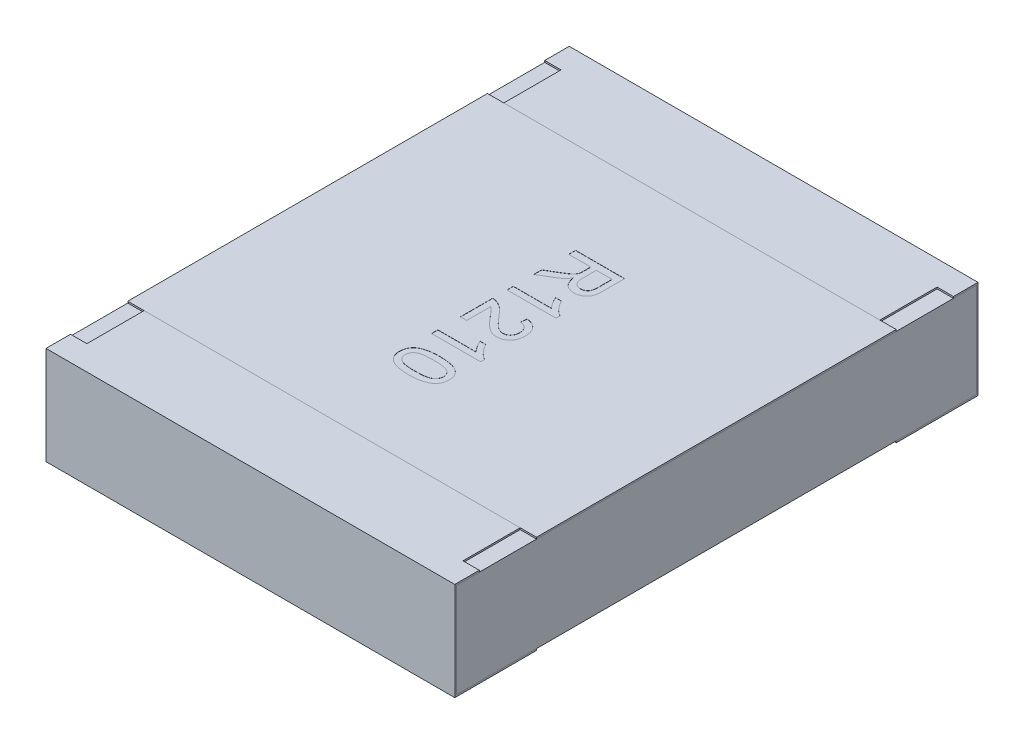
from build123d import *

# Parameters (mm, degrees)
BOSS_EXTRUDE2_DEPTH   = 1.25
BOSS_EXTRUDE2_2_DEPTH = 1.25
BOSS_EXTRUDE3_START   = -1.25
SKETCH5_W             = 3.18
SKETCH5_H             = 0.58
BOSS_EXTRUDE3_DEPTH   = 2.5
SKETCH6_W             = 0.1
SKETCH6_H             = 0.35
CUT_EXTRUDE1_DEPTH    = 0.01
SKETCH7_W             = 2.5
SKETCH7_H             = 2.2
BOSS_EXTRUDE4_DEPTH   = 0.01
TEXT1210_DEPTH        = 0.001


with BuildPart() as part:
    # Sketch4 → Boss-Extrude2 (new body, symmetric)
    with BuildSketch(Plane(origin=(0, 0, 0), x_dir=(0, 0, -1), z_dir=(1, 0, 0))):
        Polygon((-1.6, 0.3), (-1.6, -0.3), (-1.1, -0.3), (-1.1, -0.29), (-1.59, -0.29), (-1.59, 0.29), (-1.1, 0.29), (-1.1, 0.3), align=None)
    extrude(amount=BOSS_EXTRUDE2_DEPTH, both=True)


with BuildPart() as body_2:
    # Sketch4 → Boss-Extrude2 2 (new body, symmetric)
    with BuildSketch(Plane(origin=(0, 0, 0), x_dir=(0, 0, -1), z_dir=(1, 0, 0))):
        Polygon((1.1, 0.3), (1.6, 0.3), (1.6, -0.3), (1.1, -0.3), (1.1, -0.29), (1.59, -0.29), (1.59, 0.29), (1.1, 0.29), align=None)
    extrude(amount=BOSS_EXTRUDE2_2_DEPTH, both=True)


with BuildPart() as body_3:
    # Sketch5 → Boss-Extrude3 (new body)
    with BuildSketch(Plane(origin=(0, 0, 0), x_dir=(0, 0, -1), z_dir=(1, 0, 0)).offset(BOSS_EXTRUDE3_START)):
        Rectangle(SKETCH5_W, SKETCH5_H)
    extrude(amount=BOSS_EXTRUDE3_DEPTH)


with BuildPart() as cut_extrude1_tool:
    # Sketch6 → Cut-Extrude1 (new body)
    with BuildSketch(Plane(origin=(0, 0.3, 0), x_dir=(1, 0, 0), z_dir=(0, 1, 0))):
        with Locations((-1.2, 1.275)):
            Rectangle(SKETCH6_W, SKETCH6_H)
        with Locations((1.2, 1.275)):
            Rectangle(SKETCH6_W, SKETCH6_H)
        with Locations((1.2, -1.275)):
            Rectangle(SKETCH6_W, SKETCH6_H)
        with Locations((-1.2, -1.275)):
            Rectangle(SKETCH6_W, SKETCH6_H)
    extrude(amount=-CUT_EXTRUDE1_DEPTH)


with BuildPart() as part_1:
    add(part.part)

    # Cut-Extrude1: cut by cut_extrude1_tool
    add(cut_extrude1_tool.part, mode=Mode.SUBTRACT)


with BuildPart() as body_2_1:
    add(body_2.part)

    # Cut-Extrude1: cut by cut_extrude1_tool
    add(cut_extrude1_tool.part, mode=Mode.SUBTRACT)


with BuildPart() as body_4:
    # Sketch7 → Boss-Extrude4 (new body)
    with BuildSketch(Plane(origin=(0, 0.29, 0), x_dir=(1, 0, 0), z_dir=(0, 1, 0))):
        Rectangle(SKETCH7_W, SKETCH7_H)
    extrude(amount=BOSS_EXTRUDE4_DEPTH)

    # Sketch13 → TEXT1210 (cut)
    with BuildSketch(Plane(origin=(0, 0.3, 0), x_dir=(1, 0, 0), z_dir=(0, 1, 0))):
        with BuildLine():
            Line((-0.15, 0.53890045), (0.15, 0.53890045))
            Line((0.15, 0.53890045), (0.15, 0.408732181))
            add(Edge.make_bspline(
                [(0.15, 0.408732181), (0.149976098, 0.405667102), (0.149929838, 0.399735001), (0.149599275, 0.391132467), (0.148896994, 0.383121837), (0.148112632, 0.375652624), (0.146954506, 0.368737608), (0.145595815, 0.362373494), (0.14399, 0.356584693), (0.142091864, 0.351327149), (0.139945096, 0.346448918), (0.137294925, 0.34192838), (0.134395694, 0.337571787), (0.130961971, 0.333551483), (0.12726979, 0.329691487), (0.123136626, 0.326123702), (0.118620847, 0.322830716), (0.112164906, 0.318767466), (0.103522968, 0.314492001), (0.092520499, 0.310842903), (0.080987257, 0.308509851), (0.073108187, 0.308258664), (0.069110577, 0.308131219)],
                knots=[0, 0, 0, 0, 9.195e-06, 1.7797e-05, 2.5817e-05, 3.3316e-05, 4.0321e-05, 4.6839e-05, 5.2832e-05, 5.8326e-05, 6.3598e-05, 6.8794e-05, 7.4028e-05, 7.9275e-05, 8.463e-05, 9.0041e-05, 9.563e-05, 0.000101382, 0.000112912, 0.000124447, 0.00013608, 0.000148061, 0.000148061, 0.000148061, 0.000148061], degree=3))
            add(Edge.make_bspline(
                [(0.069110577, 0.308131219), (0.066544329, 0.308189925), (0.061475814, 0.308305871), (0.054023732, 0.309194023), (0.046903597, 0.310801096), (0.040052911, 0.312861739), (0.033569258, 0.315682545), (0.027318263, 0.318948853), (0.021478898, 0.323000974), (0.015856738, 0.327525677), (0.010702727, 0.332785954), (0.00594759, 0.338641486), (0.001839276, 0.345239643), (-0.001852779, 0.35245901), (-0.005083582, 0.360312684), (-0.007800008, 0.368852892), (-0.009926689, 0.378049394), (-0.010991982, 0.384426942), (-0.011538462, 0.387698527)],
                knots=[0, 0, 0, 0, 7.698e-06, 1.5204e-05, 2.2466e-05, 2.9575e-05, 3.663e-05, 4.3647e-05, 5.0697e-05, 5.7915e-05, 6.5267e-05, 7.2747e-05, 8.05e-05, 8.8536e-05, 9.7051e-05, 0.000105946, 0.000115392, 0.000125341, 0.000125341, 0.000125341, 0.000125341], degree=3))
            add(Edge.make_bspline(
                [(-0.011538462, 0.387698527), (-0.012753772, 0.385280306), (-0.01505392, 0.380703478), (-0.018746634, 0.374390533), (-0.022400996, 0.368969486), (-0.025073191, 0.365842638), (-0.026322115, 0.364381219)],
                knots=[0, 0, 0, 0, 8.117e-06, 1.5363e-05, 2.1931e-05, 2.7694e-05, 2.7694e-05, 2.7694e-05, 2.7694e-05], degree=3))
            add(Edge.make_bspline(
                [(-0.026322115, 0.364381219), (-0.029096413, 0.36154242), (-0.034786041, 0.355720511), (-0.044567018, 0.347775756), (-0.055323294, 0.339914515), (-0.06316159, 0.33519479), (-0.0671875, 0.332770643)],
                knots=[0, 0, 0, 0, 1.1899e-05, 2.4402e-05, 3.7746e-05, 5.1837e-05, 5.1837e-05, 5.1837e-05, 5.1837e-05], degree=3))
            Line((-0.0671875, 0.332770643), (-0.15, 0.283551893))
            Line((-0.15, 0.283551893), (-0.15, 0.332049489))
            Line((-0.15, 0.332049489), (-0.086658654, 0.369429296))
            add(Edge.make_bspline(
                [(-0.086658654, 0.369429296), (-0.084436284, 0.370773342), (-0.080129696, 0.373377881), (-0.073839518, 0.377139139), (-0.068050631, 0.380830263), (-0.062587585, 0.384242535), (-0.057592425, 0.387558482), (-0.052916134, 0.390591892), (-0.048743568, 0.393576151), (-0.043718189, 0.397046883), (-0.038248453, 0.401231353), (-0.03266463, 0.406147392), (-0.028105288, 0.410708943), (-0.02370073, 0.416416065), (-0.019596578, 0.423497827), (-0.017689234, 0.429504964), (-0.016766827, 0.432410066)],
                knots=[0, 0, 0, 0, 7.792e-06, 1.5099e-05, 2.1985e-05, 2.8387e-05, 3.4421e-05, 3.9972e-05, 4.5107e-05, 4.9808e-05, 5.8294e-05, 6.5746e-05, 7.212e-05, 7.7602e-05, 8.7344e-05, 9.6468e-05, 9.6468e-05, 9.6468e-05, 9.6468e-05], degree=3))
            add(Edge.make_bspline(
                [(-0.016766827, 0.432410066), (-0.016546925, 0.433629479), (-0.016044883, 0.436413437), (-0.015716998, 0.44114059), (-0.015368993, 0.446868117), (-0.015379133, 0.451018953), (-0.015384615, 0.453263431)],
                knots=[0, 0, 0, 0, 3.715e-06, 8.481e-06, 1.4198e-05, 2.0929e-05, 2.0929e-05, 2.0929e-05, 2.0929e-05], degree=3))
            Line((-0.015384615, 0.453263431), (-0.015384615, 0.496592758))
            Line((-0.015384615, 0.496592758), (-0.15, 0.496592758))
            Line((-0.15, 0.496592758), (-0.15, 0.53890045))
        make_face()
        with BuildLine():
            Line((0.019230769, 0.496592758), (0.019230769, 0.4162442))
            add(Edge.make_bspline(
                [(0.019230769, 0.4162442), (0.019294059, 0.412215272), (0.019412374, 0.404683569), (0.020415568, 0.394150896), (0.022027239, 0.385158399), (0.02434032, 0.377538233), (0.027566204, 0.371139631), (0.031574247, 0.36564263), (0.036450959, 0.360966228), (0.042058536, 0.357144318), (0.048176988, 0.354134087), (0.054649472, 0.352079121), (0.061335975, 0.350647439), (0.06589779, 0.350509036), (0.068209135, 0.350438912)],
                knots=[0, 0, 0, 0, 1.2085e-05, 2.2591e-05, 3.1702e-05, 3.9457e-05, 4.6391e-05, 5.3098e-05, 5.9771e-05, 6.6555e-05, 7.3382e-05, 8.0147e-05, 8.6889e-05, 9.3813e-05, 9.3813e-05, 9.3813e-05, 9.3813e-05], degree=3))
            add(Edge.make_bspline(
                [(0.068209135, 0.350438912), (0.069893078, 0.35049475), (0.073191429, 0.350604121), (0.078032493, 0.351177478), (0.082632622, 0.352292221), (0.087016134, 0.353764235), (0.091150922, 0.355731146), (0.095069027, 0.358067756), (0.098748733, 0.360856052), (0.102201249, 0.364049886), (0.1053427, 0.367716987), (0.108053092, 0.371905678), (0.11035634, 0.376582924), (0.112184352, 0.381754161), (0.113646463, 0.387403099), (0.114619159, 0.393561896), (0.115322998, 0.400202386), (0.115363693, 0.40480386), (0.115384615, 0.407169681)],
                knots=[0, 0, 0, 0, 5.054e-06, 9.899e-06, 1.4593e-05, 1.923e-05, 2.3746e-05, 2.8302e-05, 3.2893e-05, 3.757e-05, 4.2387e-05, 4.7338e-05, 5.2498e-05, 5.7992e-05, 6.3764e-05, 6.9978e-05, 7.6682e-05, 8.3775e-05, 8.3775e-05, 8.3775e-05, 8.3775e-05], degree=3))
            Line((0.115384615, 0.407169681), (0.115384615, 0.496592758))
            Line((0.115384615, 0.496592758), (0.019230769, 0.496592758))
        make_face(mode=Mode.SUBTRACT)
        with BuildLine():
            Line((-0.15, 0.119669681), (-0.15, 0.158131219))
            Line((-0.15, 0.158131219), (0.083774038, 0.158131219))
            add(Edge.make_bspline(
                [(0.083774038, 0.158131219), (0.081638509, 0.160345965), (0.077200045, 0.164949071), (0.070914564, 0.172727532), (0.064571645, 0.181407385), (0.058389404, 0.190844639), (0.052683492, 0.200538577), (0.047476916, 0.209878141), (0.043093554, 0.218732882), (0.040694469, 0.224563953), (0.039543269, 0.227361989)],
                knots=[0, 0, 0, 0, 9.226e-06, 1.9175e-05, 2.9969e-05, 4.147e-05, 5.3003e-05, 6.3709e-05, 7.3546e-05, 8.262e-05, 8.262e-05, 8.262e-05, 8.262e-05], degree=3))
            Line((0.039543269, 0.227361989), (0.075, 0.227361989))
            add(Edge.make_bspline(
                [(0.075, 0.227361989), (0.077475162, 0.222555868), (0.082353558, 0.21308329), (0.09077922, 0.199700585), (0.099912985, 0.18720639), (0.10975283, 0.175807534), (0.119810917, 0.165589186), (0.129959923, 0.156978036), (0.139827828, 0.149772773), (0.146709597, 0.146157756), (0.15, 0.144429296)],
                knots=[0, 0, 0, 0, 1.6212e-05, 3.1953e-05, 4.7386e-05, 6.26e-05, 7.7091e-05, 9.0349e-05, 0.000102505, 0.000113642, 0.000113642, 0.000113642, 0.000113642], degree=3))
            Line((0.15, 0.144429296), (0.15, 0.119669681))
            Line((0.15, 0.119669681), (-0.15, 0.119669681))
        make_face()
        with BuildLine():
            Line((-0.111538462, -0.164945704), (-0.15, -0.164945704))
            Line((-0.15, -0.164945704), (-0.15, 0.031208143))
            add(Edge.make_bspline(
                [(-0.15, 0.031208143), (-0.147714123, 0.031212158), (-0.14315003, 0.031220176), (-0.136400026, 0.030447858), (-0.129739566, 0.029238254), (-0.125468478, 0.027870554), (-0.123317308, 0.0271817)],
                knots=[0, 0, 0, 0, 6.852e-06, 1.3681e-05, 2.0352e-05, 2.7121e-05, 2.7121e-05, 2.7121e-05, 2.7121e-05], degree=3))
            add(Edge.make_bspline(
                [(-0.123317308, 0.0271817), (-0.119803316, 0.025907684), (-0.112648251, 0.023313576), (-0.102300861, 0.018077982), (-0.092077121, 0.011817442), (-0.083693742, 0.00582597), (-0.077044802, 0.000307816), (-0.071780052, -0.004242641), (-0.066458477, -0.00936864), (-0.06098519, -0.014976734), (-0.055359875, -0.02103289), (-0.049556317, -0.027536873), (-0.043684824, -0.034567952), (-0.039792869, -0.039476279), (-0.037800481, -0.041988973)],
                knots=[0, 0, 0, 0, 1.1205e-05, 2.2816e-05, 3.4709e-05, 4.7152e-05, 5.3684e-05, 6.0627e-05, 6.8023e-05, 7.5842e-05, 8.4134e-05, 9.2818e-05, 0.00010199, 0.00011161, 0.00011161, 0.00011161, 0.00011161], degree=3))
            add(Edge.make_bspline(
                [(-0.037800481, -0.041988973), (-0.034551471, -0.045849105), (-0.028295295, -0.053282033), (-0.019011711, -0.063778493), (-0.010391377, -0.073365301), (-0.002283205, -0.081889797), (0.005234162, -0.089421703), (0.012143692, -0.095978705), (0.018423822, -0.10161722), (0.024301865, -0.106268413), (0.029852373, -0.110192767), (0.035266551, -0.113518311), (0.040638972, -0.116289711), (0.045952637, -0.118597916), (0.05123027, -0.12042351), (0.056487246, -0.121667912), (0.061671403, -0.122511822), (0.065120999, -0.122596256), (0.066826923, -0.122638011)],
                knots=[0, 0, 0, 0, 1.5136e-05, 2.9145e-05, 4.2036e-05, 5.3811e-05, 6.4435e-05, 7.3957e-05, 8.2386e-05, 8.9745e-05, 9.643e-05, 0.000102769, 0.00010879, 0.00011455, 0.000120137, 0.000125516, 0.000130743, 0.000135857, 0.000135857, 0.000135857, 0.000135857], degree=3))
            add(Edge.make_bspline(
                [(0.066826923, -0.122638011), (0.068512943, -0.122596251), (0.071820821, -0.12251432), (0.076661881, -0.121736964), (0.081323937, -0.120654823), (0.085723062, -0.118905328), (0.089989535, -0.116822905), (0.093988521, -0.114151687), (0.097819766, -0.111061664), (0.101381944, -0.107523747), (0.104724786, -0.103659897), (0.107500012, -0.099341146), (0.110020859, -0.094841632), (0.111988045, -0.090012647), (0.113504097, -0.084897197), (0.114560258, -0.079503489), (0.115243078, -0.07381712), (0.115336721, -0.069935697), (0.115384615, -0.067950511)],
                knots=[0, 0, 0, 0, 5.054e-06, 9.915e-06, 1.4681e-05, 1.938e-05, 2.4083e-05, 2.89e-05, 3.3772e-05, 3.8829e-05, 4.3946e-05, 4.9063e-05, 5.4199e-05, 5.94e-05, 6.4667e-05, 7.0183e-05, 7.587e-05, 8.1825e-05, 8.1825e-05, 8.1825e-05, 8.1825e-05], degree=3))
            add(Edge.make_bspline(
                [(0.115384615, -0.067950511), (0.115336639, -0.065865248), (0.115242746, -0.061784233), (0.114561705, -0.055818238), (0.113515033, -0.050156984), (0.111941815, -0.044820663), (0.109882187, -0.039819946), (0.10742732, -0.035119384), (0.104518024, -0.030736949), (0.101139001, -0.026742772), (0.097458268, -0.023042921), (0.093296561, -0.01991736), (0.088872885, -0.017185193), (0.084046797, -0.015029859), (0.078924308, -0.013272117), (0.073429376, -0.012003371), (0.067585566, -0.011309945), (0.063583419, -0.011170699), (0.061538462, -0.01109955)],
                knots=[0, 0, 0, 0, 6.255e-06, 1.2241e-05, 1.7992e-05, 2.3507e-05, 2.8897e-05, 3.4193e-05, 3.9393e-05, 4.4641e-05, 4.9868e-05, 5.5012e-05, 6.0217e-05, 6.5434e-05, 7.0832e-05, 7.6444e-05, 8.2318e-05, 8.8455e-05, 8.8455e-05, 8.8455e-05, 8.8455e-05], degree=3))
            Line((0.061538462, -0.01109955), (0.065384615, 0.027361989))
            add(Edge.make_bspline(
                [(0.065384615, 0.027361989), (0.068736662, 0.026968514), (0.07525778, 0.026203042), (0.084702032, 0.024295587), (0.093489714, 0.021620518), (0.101734943, 0.018410007), (0.109336857, 0.014414645), (0.116323186, 0.009782788), (0.122725854, 0.004518046), (0.12839596, -0.001471261), (0.133571363, -0.007955893), (0.137925688, -0.015096713), (0.141698648, -0.022728063), (0.144749435, -0.030904258), (0.147087025, -0.039622088), (0.148758415, -0.048867975), (0.149789925, -0.058652385), (0.149928976, -0.065363809), (0.15, -0.068791857)],
                knots=[0, 0, 0, 0, 1.0123e-05, 1.9693e-05, 2.8857e-05, 3.7651e-05, 4.6199e-05, 5.4566e-05, 6.276e-05, 7.1006e-05, 7.9266e-05, 8.7604e-05, 9.6043e-05, 0.000104772, 0.000113738, 0.000123085, 0.000132934, 0.000143217, 0.000143217, 0.000143217, 0.000143217], degree=3))
            add(Edge.make_bspline(
                [(0.15, -0.068791857), (0.149940576, -0.072260911), (0.149824817, -0.079018649), (0.148641062, -0.08886594), (0.146795931, -0.098156453), (0.144229333, -0.106927372), (0.140839664, -0.115132097), (0.136757117, -0.122798722), (0.131911514, -0.12990297), (0.126324053, -0.136348396), (0.120221623, -0.142160815), (0.113705953, -0.147247068), (0.106829733, -0.151523142), (0.099612825, -0.155060041), (0.092008541, -0.157768278), (0.084045391, -0.159653026), (0.075742745, -0.160939575), (0.070077161, -0.161045516), (0.0671875, -0.16109955)],
                knots=[0, 0, 0, 0, 1.0403e-05, 2.0265e-05, 2.9705e-05, 3.8794e-05, 4.7633e-05, 5.6291e-05, 6.4808e-05, 7.3373e-05, 8.1833e-05, 9.0055e-05, 9.8126e-05, 0.000106082, 0.000114122, 0.000122285, 0.000130605, 0.000139266, 0.000139266, 0.000139266, 0.000139266], degree=3))
            add(Edge.make_bspline(
                [(0.0671875, -0.16109955), (0.064218398, -0.161018436), (0.05827364, -0.16085603), (0.049399233, -0.159540755), (0.040594357, -0.15742356), (0.03178904, -0.15448579), (0.02297561, -0.150397344), (0.013942435, -0.1453621), (0.004756402, -0.139068729), (-0.003111225, -0.133100478), (-0.009660413, -0.127481214), (-0.015062592, -0.122500411), (-0.020824791, -0.116739332), (-0.027059821, -0.110351181), (-0.033675497, -0.103205116), (-0.04077151, -0.095431357), (-0.048197577, -0.086875504), (-0.053269547, -0.080934925), (-0.055889423, -0.077866377)],
                knots=[0, 0, 0, 0, 8.904e-06, 1.7828e-05, 2.6851e-05, 3.6049e-05, 4.5623e-05, 5.5954e-05, 6.7039e-05, 7.8998e-05, 8.5562e-05, 9.292e-05, 0.000101036, 0.000110004, 0.000119698, 0.000130249, 0.000141579, 0.000153683, 0.000153683, 0.000153683, 0.000153683], degree=3))
            add(Edge.make_bspline(
                [(-0.055889423, -0.077866377), (-0.058028577, -0.075238679), (-0.062107615, -0.070228065), (-0.068021764, -0.063100065), (-0.073442596, -0.056713575), (-0.07820298, -0.05092774), (-0.082492694, -0.045938601), (-0.086224809, -0.04163915), (-0.089451821, -0.038072078), (-0.094402484, -0.03263426), (-0.10140021, -0.025694591), (-0.108253196, -0.020622443), (-0.111538462, -0.018190896)],
                knots=[0, 0, 0, 0, 1.0165e-05, 1.9383e-05, 2.7786e-05, 3.5295e-05, 4.1859e-05, 4.7524e-05, 5.2375e-05, 5.6288e-05, 6.9591e-05, 8.184e-05, 8.184e-05, 8.184e-05, 8.184e-05], degree=3))
            Line((-0.111538462, -0.018190896), (-0.111538462, -0.164945704))
        make_face()
        with BuildLine():
            Line((-0.15, -0.341868781), (-0.15, -0.303407242))
            Line((-0.15, -0.303407242), (0.083774038, -0.303407242))
            add(Edge.make_bspline(
                [(0.083774038, -0.303407242), (0.081638509, -0.301192496), (0.077200045, -0.29658939), (0.070914564, -0.28881093), (0.064571645, -0.280131077), (0.058389404, -0.270693823), (0.052683492, -0.260999885), (0.047476916, -0.251660321), (0.043093554, -0.242805579), (0.040694469, -0.236974509), (0.039543269, -0.234176473)],
                knots=[0, 0, 0, 0, 9.226e-06, 1.9175e-05, 2.9969e-05, 4.147e-05, 5.3003e-05, 6.3709e-05, 7.3546e-05, 8.262e-05, 8.262e-05, 8.262e-05, 8.262e-05], degree=3))
            Line((0.039543269, -0.234176473), (0.075, -0.234176473))
            add(Edge.make_bspline(
                [(0.075, -0.234176473), (0.077475162, -0.238982593), (0.082353558, -0.248455172), (0.09077922, -0.261837877), (0.099912985, -0.274332071), (0.10975283, -0.285730927), (0.119810917, -0.295949275), (0.129959923, -0.304560426), (0.139827828, -0.311765688), (0.146709597, -0.315380705), (0.15, -0.317109165)],
                knots=[0, 0, 0, 0, 1.6212e-05, 3.1953e-05, 4.7386e-05, 6.26e-05, 7.7091e-05, 9.0349e-05, 0.000102505, 0.000113642, 0.000113642, 0.000113642, 0.000113642], degree=3))
            Line((0.15, -0.317109165), (0.15, -0.341868781))
            Line((0.15, -0.341868781), (-0.15, -0.341868781))
        make_face()
        with BuildLine():
            add(Edge.make_bspline(
                [(-0.002043269, -0.438022627), (0.002244006, -0.438061377), (0.010640973, -0.438137272), (0.022927245, -0.438608023), (0.034595007, -0.439429919), (0.045634132, -0.440656776), (0.05606952, -0.442109626), (0.065886336, -0.443998266), (0.075106414, -0.446123507), (0.083720798, -0.448672551), (0.091801288, -0.451476047), (0.099342803, -0.454646404), (0.106300734, -0.458244835), (0.112864039, -0.461946855), (0.118725274, -0.466256953), (0.12425569, -0.470627912), (0.129139599, -0.475506772), (0.133536862, -0.480661493), (0.137415967, -0.486177503), (0.140763485, -0.492023121), (0.143719015, -0.498176519), (0.145943958, -0.504754793), (0.147757752, -0.511621429), (0.149092003, -0.518829269), (0.149878588, -0.526386259), (0.149959072, -0.531550399), (0.15, -0.534176473)],
                knots=[0, 0, 0, 0, 1.2862e-05, 2.5191e-05, 3.688e-05, 4.7943e-05, 5.8507e-05, 6.8478e-05, 7.7924e-05, 8.6881e-05, 9.5415e-05, 0.000103574, 0.000111395, 0.000118909, 0.000126147, 0.000133195, 0.000140037, 0.000146816, 0.000153502, 0.000160233, 0.000167008, 0.000173945, 0.000181029, 0.000188302, 0.000195914, 0.00020379, 0.00020379, 0.00020379, 0.00020379], degree=3))
            add(Edge.make_bspline(
                [(0.15, -0.534176473), (0.149886629, -0.538029195), (0.149663908, -0.545598023), (0.147850494, -0.556649726), (0.144740696, -0.56706077), (0.140578188, -0.576829525), (0.135193656, -0.585744763), (0.128816305, -0.593804967), (0.121179131, -0.60068447), (0.11253276, -0.60661052), (0.102860028, -0.611692108), (0.092252026, -0.616237796), (0.080663785, -0.620313429), (0.070320072, -0.623296616), (0.061375886, -0.625388093), (0.053985027, -0.626661444), (0.046034731, -0.627837115), (0.03750596, -0.628670447), (0.028438575, -0.62951843), (0.018793038, -0.62993709), (0.008575899, -0.630256589), (0.001562812, -0.630305282), (-0.002043269, -0.630330319)],
                knots=[0, 0, 0, 0, 1.1554e-05, 2.2698e-05, 3.348e-05, 4.4085e-05, 5.4464e-05, 6.4638e-05, 7.4805e-05, 8.5173e-05, 9.6008e-05, 0.000107529, 0.00011977, 0.000132837, 0.000139806, 0.000147315, 0.000155329, 0.00016391, 0.000173019, 0.000182646, 0.000192867, 0.000203685, 0.000203685, 0.000203685, 0.000203685], degree=3))
            add(Edge.make_bspline(
                [(-0.002043269, -0.630330319), (-0.00631044, -0.630291062), (-0.014647199, -0.630214365), (-0.026834487, -0.629753192), (-0.03841587, -0.628892456), (-0.049405471, -0.627783273), (-0.059813481, -0.626289897), (-0.069614428, -0.624423349), (-0.078820333, -0.622267484), (-0.087440482, -0.619827827), (-0.095486737, -0.616989463), (-0.102997606, -0.613788164), (-0.110046684, -0.610355426), (-0.116502689, -0.606461768), (-0.122472492, -0.602314791), (-0.127974887, -0.597875751), (-0.132931669, -0.593052701), (-0.137314485, -0.587849865), (-0.141263346, -0.582373231), (-0.144641302, -0.576512422), (-0.147459366, -0.570281147), (-0.149814671, -0.563734944), (-0.151604655, -0.556830361), (-0.15293367, -0.549603376), (-0.153727476, -0.542006837), (-0.153806049, -0.536822606), (-0.153846154, -0.534176473)],
                knots=[0, 0, 0, 0, 1.2802e-05, 2.5011e-05, 3.658e-05, 4.7637e-05, 5.8141e-05, 6.8112e-05, 7.7558e-05, 8.6498e-05, 9.4975e-05, 0.000103135, 0.000110983, 0.000118475, 0.000125727, 0.000132776, 0.000139661, 0.00014644, 0.00015316, 0.000159891, 0.000166695, 0.000173652, 0.000180737, 0.000188068, 0.000195681, 0.000203617, 0.000203617, 0.000203617, 0.000203617], degree=3))
            add(Edge.make_bspline(
                [(-0.153846154, -0.534176473), (-0.153747192, -0.530707163), (-0.153554242, -0.523942964), (-0.152243272, -0.51406435), (-0.149935902, -0.504792743), (-0.146841394, -0.496049944), (-0.142702311, -0.487934223), (-0.137666308, -0.480406832), (-0.131850554, -0.473316512), (-0.127262057, -0.469234893), (-0.124939904, -0.467169261)],
                knots=[0, 0, 0, 0, 1.0408e-05, 2.0292e-05, 2.9825e-05, 3.9025e-05, 4.8056e-05, 5.7073e-05, 6.616e-05, 7.5471e-05, 7.5471e-05, 7.5471e-05, 7.5471e-05], degree=3))
            add(Edge.make_bspline(
                [(-0.124939904, -0.467169261), (-0.121510195, -0.464791671), (-0.11443799, -0.459888979), (-0.102379223, -0.454150803), (-0.089104214, -0.449032248), (-0.074352508, -0.445015121), (-0.058241513, -0.441868709), (-0.040739616, -0.439596214), (-0.021854376, -0.438310205), (-0.008796046, -0.43812065), (-0.002043269, -0.438022627)],
                knots=[0, 0, 0, 0, 1.2501e-05, 2.5778e-05, 3.993e-05, 5.5152e-05, 7.157e-05, 8.9147e-05, 0.000108063, 0.000128321, 0.000128321, 0.000128321, 0.000128321], degree=3))
        make_face()
        with BuildLine():
            add(Edge.make_bspline(
                [(-0.001923077, -0.476484165), (-0.007693168, -0.476522354), (-0.018738399, -0.476595457), (-0.034518417, -0.477359203), (-0.048754147, -0.478673959), (-0.061425879, -0.480412153), (-0.072550754, -0.482707272), (-0.082100422, -0.485589066), (-0.090189501, -0.488837534), (-0.096717734, -0.49285745), (-0.102039196, -0.497258815), (-0.106615825, -0.501802924), (-0.110505855, -0.506596683), (-0.113749347, -0.511608814), (-0.116205105, -0.516917084), (-0.117985045, -0.522463448), (-0.119009373, -0.528249112), (-0.119156549, -0.532189413), (-0.119230769, -0.534176473)],
                knots=[0, 0, 0, 0, 1.7309e-05, 3.3134e-05, 4.7378e-05, 6.0186e-05, 7.1489e-05, 8.1413e-05, 9.0085e-05, 9.7558e-05, 0.000104306, 0.000110765, 0.000116876, 0.000122794, 0.000128628, 0.000134368, 0.000140227, 0.000146187, 0.000146187, 0.000146187, 0.000146187], degree=3))
            add(Edge.make_bspline(
                [(-0.119230769, -0.534176473), (-0.119154928, -0.536163035), (-0.119004535, -0.540102349), (-0.118002795, -0.545901382), (-0.116131225, -0.551426166), (-0.11368414, -0.556726521), (-0.110514577, -0.561775082), (-0.106609854, -0.566545298), (-0.102035942, -0.571113344), (-0.096652628, -0.575494938), (-0.090094213, -0.579484228), (-0.082011723, -0.582793633), (-0.072445331, -0.585630516), (-0.061326124, -0.587938229), (-0.048674427, -0.589683593), (-0.03447818, -0.590990401), (-0.018718466, -0.591759257), (-0.007693194, -0.591831153), (-0.001923077, -0.591868781)],
                knots=[0, 0, 0, 0, 5.96e-06, 1.1819e-05, 1.7578e-05, 2.3412e-05, 2.9298e-05, 3.5408e-05, 4.1867e-05, 4.8662e-05, 5.6186e-05, 6.4803e-05, 7.4784e-05, 8.6088e-05, 9.8836e-05, 0.00011308, 0.000128845, 0.000146154, 0.000146154, 0.000146154, 0.000146154], degree=3))
            add(Edge.make_bspline(
                [(-0.001923077, -0.591868781), (0.003726983, -0.591832359), (0.014552285, -0.591762576), (0.030028294, -0.590973883), (0.044025103, -0.58973796), (0.056555506, -0.588047323), (0.067606248, -0.585800753), (0.077199767, -0.583075105), (0.085318952, -0.579829735), (0.09203502, -0.575962852), (0.097578912, -0.571675376), (0.102284051, -0.567120043), (0.106407321, -0.562385009), (0.109635927, -0.557199684), (0.11228385, -0.551784506), (0.114056455, -0.54602339), (0.1151941, -0.539990724), (0.115320181, -0.535864506), (0.115384615, -0.5337558)],
                knots=[0, 0, 0, 0, 1.6949e-05, 3.2473e-05, 4.6473e-05, 5.9094e-05, 7.0385e-05, 8.0274e-05, 8.8979e-05, 9.6545e-05, 0.000103444, 0.000109947, 0.000116172, 0.000122224, 0.000128218, 0.000134205, 0.000140252, 0.000146573, 0.000146573, 0.000146573, 0.000146573], degree=3))
            add(Edge.make_bspline(
                [(0.115384615, -0.5337558), (0.115332466, -0.531768865), (0.115229635, -0.527850883), (0.114248109, -0.522114445), (0.112606778, -0.51667809), (0.110383437, -0.511479535), (0.107391258, -0.506648559), (0.103897677, -0.501993578), (0.099641138, -0.497732613), (0.096459016, -0.495164993), (0.094831731, -0.493851954)],
                knots=[0, 0, 0, 0, 5.957e-06, 1.1747e-05, 1.7393e-05, 2.2965e-05, 2.8654e-05, 3.4399e-05, 4.0391e-05, 4.6662e-05, 4.6662e-05, 4.6662e-05, 4.6662e-05], degree=3))
            add(Edge.make_bspline(
                [(0.094831731, -0.493851954), (0.092441753, -0.492422455), (0.087394622, -0.489403654), (0.078622501, -0.486025791), (0.068597636, -0.48304192), (0.057165788, -0.480585206), (0.044346567, -0.478807945), (0.03015486, -0.477404866), (0.014570853, -0.476676019), (0.003726591, -0.476549881), (-0.001923077, -0.476484165)],
                knots=[0, 0, 0, 0, 8.341e-06, 1.7615e-05, 2.8091e-05, 3.9714e-05, 5.2649e-05, 6.6899e-05, 8.2483e-05, 9.9433e-05, 9.9433e-05, 9.9433e-05, 9.9433e-05], degree=3))
        make_face(mode=Mode.SUBTRACT)
    extrude(amount=-TEXT1210_DEPTH, mode=Mode.SUBTRACT)


solid = Compound([body_3.part, part_1.part, body_2_1.part, body_4.part])
